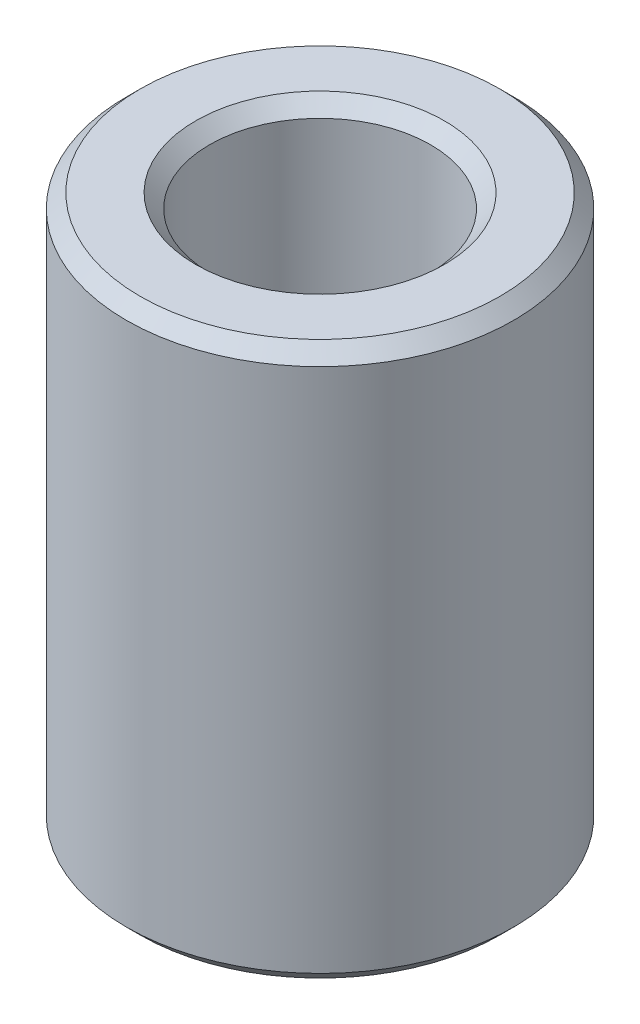
from build123d import *

# Parameters (mm, degrees)
CROQUIS1_R              = 7
CROQUIS1_R_2            = 4
SALIENTE_EXTRUIR1_DEPTH = 20
CHAFL_N1_SIZE           = 0.5


with BuildPart() as part:
    # Croquis1 → Saliente-Extruir1 (new body)
    with BuildSketch(Plane(origin=(0, 0, 0), x_dir=(1, 0, 0), z_dir=(0, 1, 0))):
        Circle(CROQUIS1_R)
        Circle(CROQUIS1_R_2, mode=Mode.SUBTRACT)
    extrude(amount=SALIENTE_EXTRUIR1_DEPTH)

    # Chaflán1
    chafl_n1_edges = [part.edges().sort_by_distance(p)[0] for p in [
        (-7, 0, 0),
        (-7, 20, 0),
        (-4, 0, 0),
        (-4, 20, 0),
    ]]
    chamfer(chafl_n1_edges, length=CHAFL_N1_SIZE)


solid = part.part
